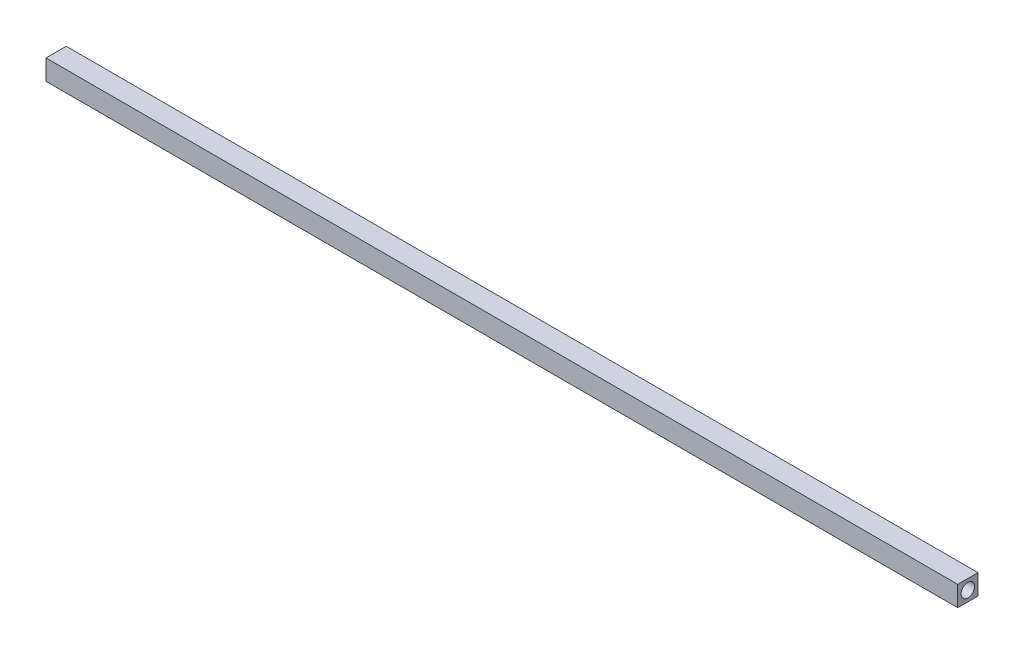
from build123d import *

# Parameters (mm, degrees)
SKETCH_1_W      = 3
SKETCH_1_H      = 3
SKETCH_1_R      = 1
EXTRUDE_1_DEPTH = 135


with BuildPart() as part:
    # 草图1 → 凸台-拉伸1 (new body)
    with BuildSketch(Plane(origin=(0, 0, 0), x_dir=(0, 0, -1), z_dir=(1, 0, 0))):
        Rectangle(SKETCH_1_W, SKETCH_1_H)
        Circle(SKETCH_1_R, mode=Mode.SUBTRACT)
    extrude(amount=EXTRUDE_1_DEPTH)


solid = part.part
